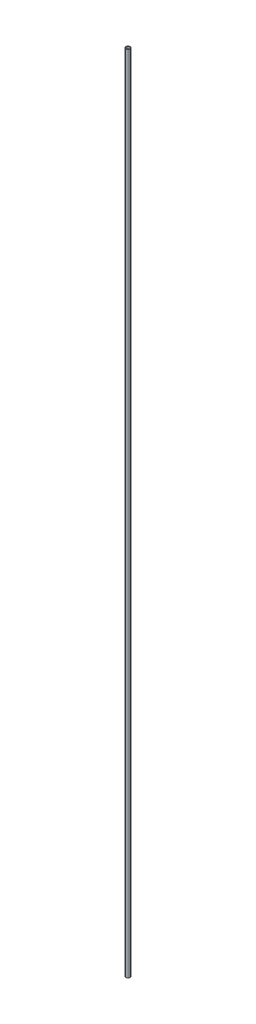
from build123d import *

# Parameters (mm, degrees)
SKETCH1_R           = 3.6195
SKETCH1_R_2         = 2.8575
BOSS_EXTRUDE1_DEPTH = 1397


with BuildPart() as part:
    # Sketch1 → Boss-Extrude1 (new body)
    with BuildSketch(Plane(origin=(0, 0, 0), x_dir=(1, 0, 0), z_dir=(0, 1, 0))):
        Circle(SKETCH1_R)
        Circle(SKETCH1_R_2, mode=Mode.SUBTRACT)
    extrude(amount=BOSS_EXTRUDE1_DEPTH)


solid = part.part
